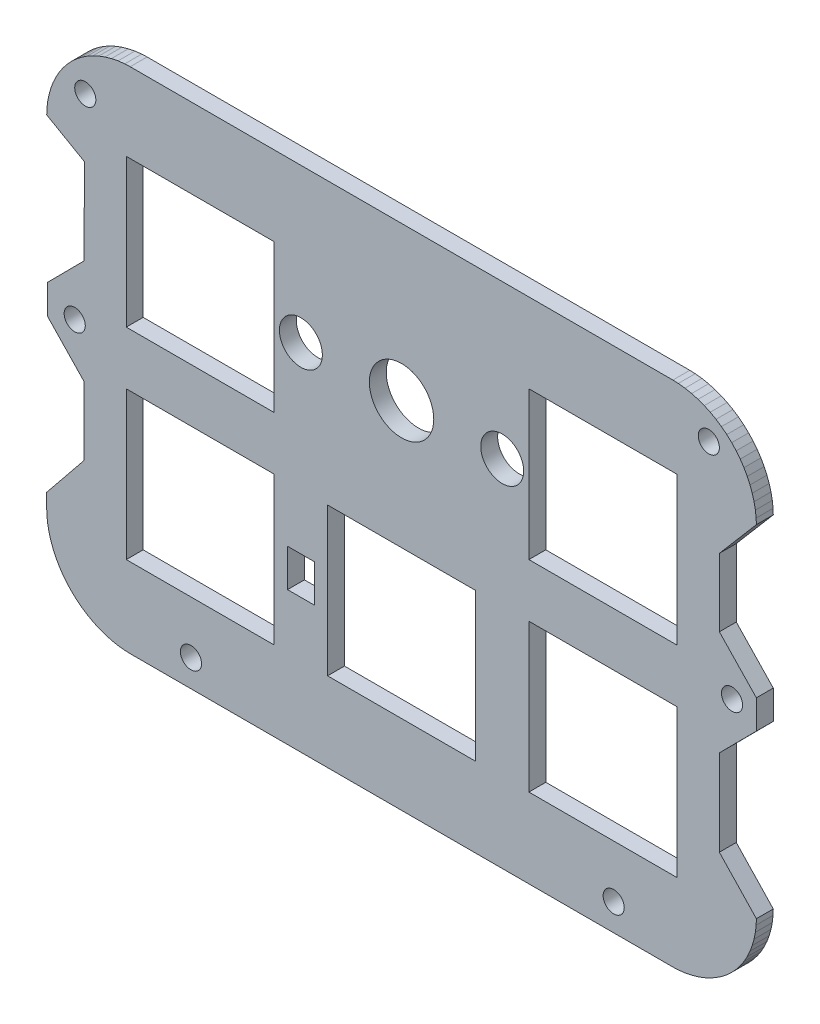
from build123d import *

# Parameters (mm, degrees)
MODEL_R         = 2.032
MODEL_R_2       = 3.048
MODEL_R_3       = 1
MODEL_W         = 13.99947
MODEL_H         = 13.99944
MODEL_W_2       = 13.9993
MODEL_H_2       = 13.9993
MODEL_W_3       = 13.9994
MODEL_W_4       = 2.54
MODEL_H_3       = 3.556
EXTRUDE_1_DEPTH = 1.6


with BuildPart() as part:
    # Model → 凸台-拉伸1 (new body)
    with BuildSketch(Plane.XY):
        Polygon((-4.883883532, 35.973891408), (-4.813241799, 36.606032798), (-4.68610198, 37.230158431), (-4.516543388, 37.837883816), (-4.295846464, 38.426181173), (-4.040425316, 38.98432755), (-3.734657976, 39.530581217), (-3.38546168, 40.058138925), (-2.991401911, 40.556139441), (-2.564669958, 41.019308228), (-2.102117382, 41.445002794), (-1.607054067, 41.836688867), (-1.079854091, 42.186395311), (-0.531138892, 42.493537781), (0.027842562, 42.749214223), (0.615268756, 42.969285901), (1.221866946, 43.138689477), (1.847538347, 43.266199966), (2.481438717, 43.33682275), (2.994321582, 43.3575), (54.345328535, 43.3575), (54.861412529, 43.336821814), (55.491753218, 43.266152175), (56.117576842, 43.139310654), (56.726490724, 42.969125656), (57.312630049, 42.749556004), (57.878545004, 42.490950339), (58.425461808, 42.18272689), (58.9399975, 41.841630195), (59.445802193, 41.444115049), (59.912079101, 41.011414411), (60.332093164, 40.555391632), (60.716064737, 40.069904287), (61.069053534, 39.543781609), (61.382985177, 38.982666106), (61.644423874, 38.410551538), (61.855071366, 37.838089056), (62.028284371, 37.232642984), (62.152332548, 36.60558626), (62.225027392, 35.986226197), (62.246303139, 35.458587663), (58.746175407, 31.358234918), (58.745975132, 24.929084585), (62.245861062, 21.267199282), (62.245579127, 18.534705638), (58.745666056, 15.007268129), (58.745412398, 6.86443549), (62.245297192, 3.166071528), (62.226202972, 2.636734827), (62.152356641, 2.011350393), (62.029241049, 1.384922025), (61.855333273, 0.776565869), (61.644240363, 0.202684675), (61.379380282, -0.376374826), (61.064717919, -0.934798534), (60.721224007, -1.446690794), (60.332973054, -1.941418241), (59.905767444, -2.401934126), (59.445938304, -2.8287768), (58.947571314, -3.220379587), (58.434482529, -3.563431063), (57.880206411, -3.875955859), (57.302144081, -4.140491025), (56.726168878, -4.352867841), (56.11599848, -4.526806688), (55.492240411, -4.649391053), (54.87843401, -4.722059086), (54.34686609, -4.743685), (2.992774524, -4.743685), (2.464503115, -4.722060038), (1.847223482, -4.64943937), (1.223529929, -4.526191258), (0.615600502, -4.353028424), (0.038326794, -4.140153507), (-0.532800957, -3.878547051), (-1.088890304, -3.567123565), (-1.614610519, -3.215411153), (-2.102251702, -2.829663369), (-2.558331876, -2.409802006), (-2.992281832, -1.942165148), (-3.390574278, -1.434889052), (-3.730362364, -0.921623746), (-4.03681533, -0.378036856), (-4.295659415, 0.187060206), (-4.516803943, 0.776764684), (-4.687062167, 1.387481119), (-4.813264805, 2.011073476), (-4.883883595, 2.639206616), (-4.9049154, 3.15597541), (-4.9049154, 4.538497879), (-1.354024868, 8.929084585), (-1.353649461, 15.358051679), (-4.853710523, 19.020120221), (-4.853428588, 21.752613865), (-1.353515518, 25.280051374), (-1.35326186, 33.422884013), (-4.9049154, 35.460217069), align=None)
        with Locations((38.1958, 28.832)):
            Circle(MODEL_R, mode=Mode.SUBTRACT)
        with Locations((19.1458, 28.832)):
            Circle(MODEL_R, mode=Mode.SUBTRACT)
        with Locations((28.6708, 28.832)):
            Circle(MODEL_R_2, mode=Mode.SUBTRACT)
        with Locations((-2.255498735, 20.010211418)):
            Circle(MODEL_R_3, mode=Mode.SUBTRACT)
        with Locations((-1.255498735, 39.010211418)):
            Circle(MODEL_R_3, mode=Mode.SUBTRACT)
        with Locations((57.744501265, 40.010211418)):
            Circle(MODEL_R_3, mode=Mode.SUBTRACT)
        with Locations((59.944501265, 20.010211418)):
            Circle(MODEL_R_3, mode=Mode.SUBTRACT)
        with Locations((8.744501265, -2.189788582)):
            Circle(MODEL_R_3, mode=Mode.SUBTRACT)
        with Locations((48.744501265, -2.189788582)):
            Circle(MODEL_R_3, mode=Mode.SUBTRACT)
        with Locations((9.620765, 9.78198)):
            Rectangle(MODEL_W, MODEL_H, mode=Mode.SUBTRACT)
        with Locations((47.72075, 28.83195)):
            Rectangle(MODEL_W_2, MODEL_H_2, mode=Mode.SUBTRACT)
        with Locations((28.6707, 9.78198)):
            Rectangle(MODEL_W_3, MODEL_H, mode=Mode.SUBTRACT)
        with Locations((9.620765, 28.83195)):
            Rectangle(MODEL_W, MODEL_H_2, mode=Mode.SUBTRACT)
        with Locations((47.72075, 9.78198)):
            Rectangle(MODEL_W_2, MODEL_H, mode=Mode.SUBTRACT)
        with Locations((19.151523106, 9.728566018)):
            Rectangle(MODEL_W_4, MODEL_H_3, mode=Mode.SUBTRACT)
    extrude(amount=EXTRUDE_1_DEPTH)


solid = part.part
